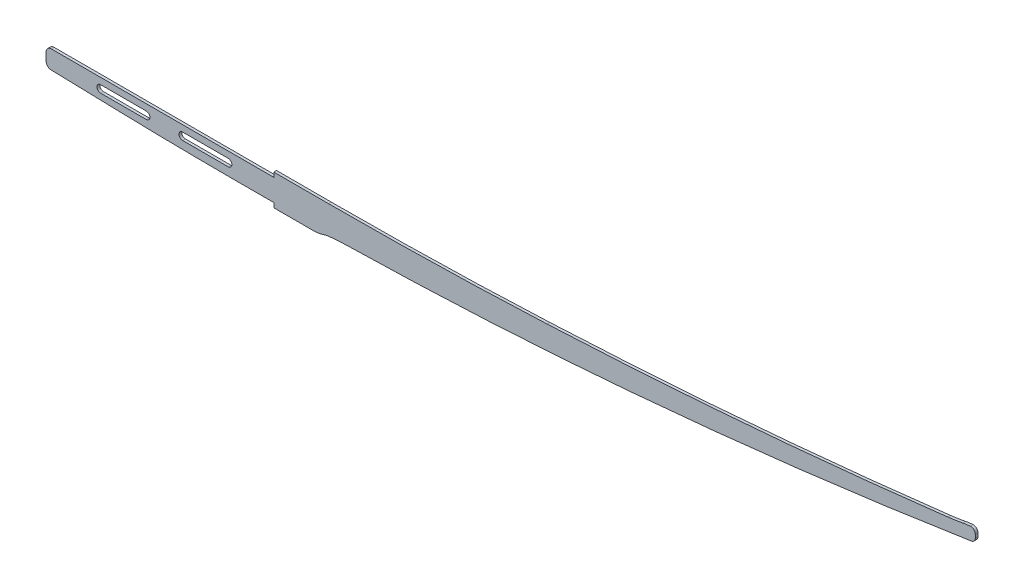
from build123d import *

# Parameters (mm, degrees)
EXTRUDE_1_DEPTH = 1.5


with BuildPart() as part:
    # 草图1 → 凸台-拉伸1 (new body, symmetric)
    with BuildSketch(Plane.XY):
        with BuildLine():
            Line((0, 12), (-244, 12))
            ThreePointArc((-244, 12), (-248.242640687, 10.242640687), (-250, 6))
            Line((-250, 6), (-250, -2.163248404))
            ThreePointArc((-250, -2.163248404), (-248.300744725, -6.346978177), (-244.165468396, -8.160966321))
            Line((-244.165468396, -8.160966321), (-170, -10.207084742))
            ThreePointArc((-170, -10.207084742), (-105.006181524, -11.551749873), (-40, -12))
            Line((-40, -12), (0, -12))
            Line((0, -12), (0, -17))
            Line((0, -17), (44.145576966, -17))
            ThreePointArc((44.145576966, -17), (49.047286744, -16.596845123), (53.817253308, -15.398216084))
            ThreePointArc((53.817253308, -15.398216084), (56.87159336, -14.535351182), (60, -14))
            ThreePointArc((60, -14), (69.983522822, -13.072941186), (80, -12.625335423))
            ThreePointArc((80, -12.625335423), (235.133064328, -6.904453143), (390, 3.82999502))
            ThreePointArc((390, 3.82999502), (578.273151109, 23.21141529), (765.76796239, 49.059328612))
            ThreePointArc((765.76796239, 49.059328612), (768.797355129, 50.747294353), (770, 54))
            Line((770, 54), (770, 57.675354294))
            ThreePointArc((770, 57.675354294), (768.391164992, 61.349588908), (764.6, 62.659328612))
            ThreePointArc((764.6, 62.659328612), (760.284727379, 62.197558708), (756, 61.507688779))
            ThreePointArc((756, 61.507688779), (748.020565474, 60.142412099), (740, 59.044284039))
            ThreePointArc((740, 59.044284039), (520.334050184, 36.766259367), (300, 22.541414161))
            ThreePointArc((300, 22.541414161), (180.031982479, 18.385538128), (60, 17))
            Line((60, 17), (0, 17))
            Line((0, 17), (0, 12))
        make_face()
        with BuildLine():
            Line((-50, -3), (-100, -3))
            ThreePointArc((-100, -3), (-104, 1), (-100, 5))
            Line((-100, 5), (-50, 5))
            ThreePointArc((-50, 5), (-46, 1), (-50, -3))
        make_face(mode=Mode.SUBTRACT)
        with BuildLine():
            Line((-140, -3), (-190, -3))
            ThreePointArc((-190, -3), (-194, 1), (-190, 5))
            Line((-190, 5), (-140, 5))
            ThreePointArc((-140, 5), (-136, 1), (-140, -3))
        make_face(mode=Mode.SUBTRACT)
    extrude(amount=EXTRUDE_1_DEPTH, both=True)


solid = part.part
